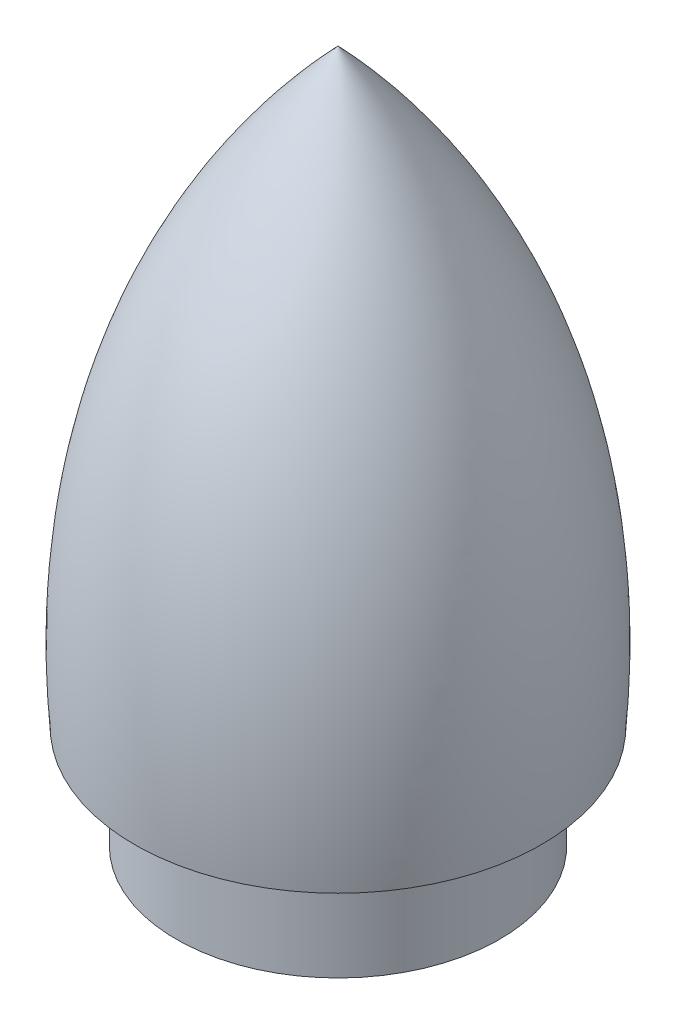
from build123d import *


with BuildPart() as part:
    # Sketch2 → Revolve2 (revolve)
    with BuildSketch(Plane.XY):
        with BuildLine():
            Line((-15.100803511, 43.266192878), (-12, 43.318318188))
            Line((-12, 43.318318188), (-12, 35.628172116))
            Line((-12, 35.628172116), (0, 35.628172116))
            Line((0, 35.628172116), (0, 87.040082592))
            add(Edge.make_bspline(
                [(0, 87.040082592), (-17.156536589, 69.152077158), (-15.100803511, 43.266192878)],
                knots=[0, 0, 0, 1, 1, 1], degree=2))
        make_face()
    revolve(axis=Axis((0, 35.628172116, 0), (0, 1, 0)))


solid = part.part
